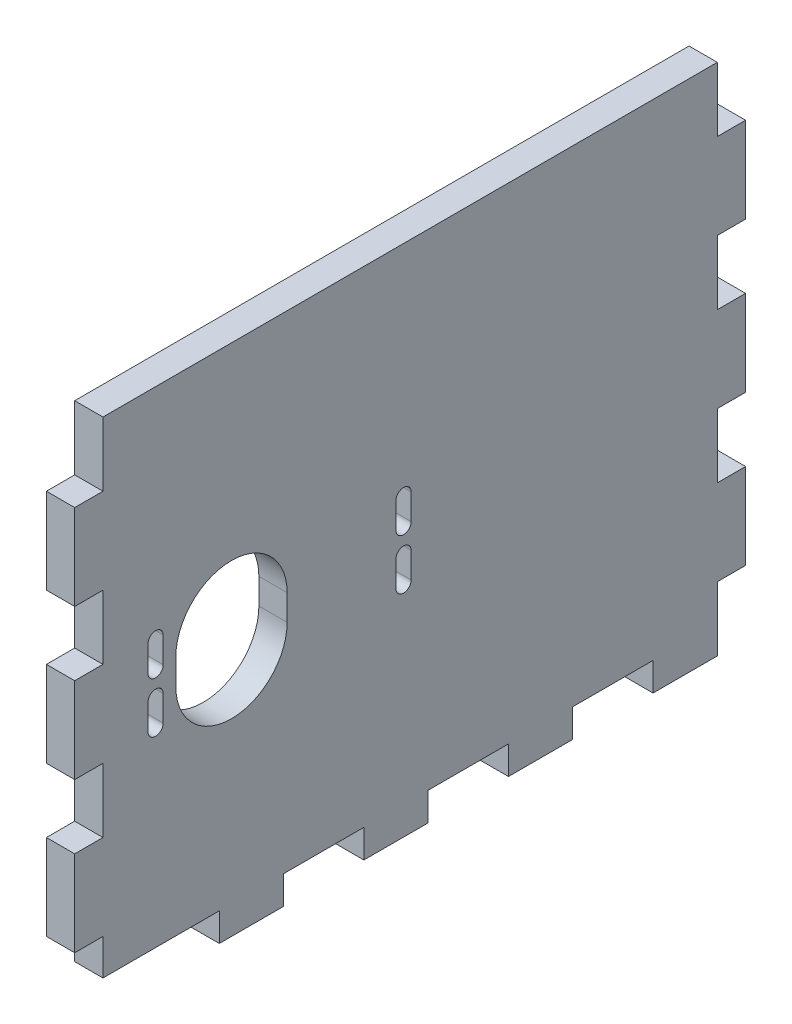
from build123d import *

# Parameters (mm, degrees)
SKETCH1_W               = 44.958
SKETCH1_H               = 304.8
BOSS_EXTRUDE1_DEPTH     = 5.588
BOSS_EXTRUDE2_DEPTH     = 5.588
SKETCH3_W               = 121.412
SKETCH3_H               = 5.588
BOSS_EXTRUDE3_DEPTH     = 39.37
SKETCH8_W               = 5.588
SKETCH8_H               = 213.451350416
CUT_EXTRUDE4_DEPTH      = 1
CUT_EXTRUDE4_DEPTH_BACK = 133.588
SKETCH6_W               = 5.588
SKETCH6_H               = 12.7
CUT_EXTRUDE5_DEPTH      = 5.588
SKETCH4_3_W             = 6.35
SKETCH4_3_H             = 15.875
SKETCH4_3_H_2           = 5.588
SKETCH4_3_H_3           = 7.112
CUT_EXTRUDE6_DEPTH      = 5.588


with BuildPart() as part:
    # Sketch1 → Boss-Extrude1 (new body)
    with BuildSketch(Plane.XY):
        with Locations((-6.477, 3.048)):
            Rectangle(SKETCH1_W, SKETCH1_H)
        with BuildLine():
            Line((-3.302, 133.858), (-3.302, -143.002))
            Line((-3.302, -143.002), (3.302, -143.002))
            Line((3.302, -143.002), (3.302, 143.002))
            Line((3.302, 143.002), (-16.256, 143.002))
            Line((-16.256, 143.002), (-16.256, 136.398))
            Line((-16.256, 136.398), (-5.842, 136.398))
            ThreePointArc((-5.842, 136.398), (-4.045948776, 135.654051224), (-3.302, 133.858))
        make_face(mode=Mode.SUBTRACT)
    extrude(amount=BOSS_EXTRUDE1_DEPTH)

    # Sketch2 → Boss-Extrude2 (add)
    with BuildSketch(Plane(origin=(16.002, 0, 0), x_dir=(0, 0, -1), z_dir=(1, 0, 0))):
        Polygon((121.412, -47.752), (-5.588, -47.752), (-5.588, -149.352), (121.412, -149.352), (121.412, -136.652), (127, -136.652), (127, -119.718666667), (121.412, -119.718666667), (121.412, -107.018666667), (127, -107.018666667), (127, -90.085333333), (121.412, -90.085333333), (121.412, -77.385333333), (127, -77.385333333), (127, -60.452), (121.412, -60.452), align=None)
        with BuildLine():
            ThreePointArc((11.9, -106.092), (10.4, -107.592), (8.9, -106.092))
            Line((8.9, -106.092), (8.9, -101.012))
            ThreePointArc((8.9, -101.012), (10.4, -99.512), (11.9, -101.012))
            Line((11.9, -101.012), (11.9, -106.092))
        make_face(mode=Mode.SUBTRACT)
        with BuildLine():
            ThreePointArc((60.9, -106.092), (59.4, -107.592), (57.9, -106.092))
            Line((57.9, -106.092), (57.9, -101.012))
            ThreePointArc((57.9, -101.012), (59.4, -99.512), (60.9, -101.012))
            Line((60.9, -101.012), (60.9, -106.092))
        make_face(mode=Mode.SUBTRACT)
        with BuildLine():
            Line((8.9, -96.092), (8.9, -91.012))
            ThreePointArc((8.9, -91.012), (10.4, -89.512), (11.9, -91.012))
            Line((11.9, -91.012), (11.9, -96.092))
            ThreePointArc((11.9, -96.092), (10.4, -97.592), (8.9, -96.092))
        make_face(mode=Mode.SUBTRACT)
        with BuildLine():
            ThreePointArc((36.4, -101.092), (25.4, -112.092), (14.4, -101.092))
            Line((14.4, -101.092), (14.4, -96.012))
            ThreePointArc((14.4, -96.012), (25.4, -85.012), (36.4, -96.012))
            Line((36.4, -96.012), (36.4, -101.092))
        make_face(mode=Mode.SUBTRACT)
        with BuildLine():
            ThreePointArc((57.9, -91.012), (59.4, -89.512), (60.9, -91.012))
            Line((60.9, -91.012), (60.9, -96.092))
            ThreePointArc((60.9, -96.092), (59.4, -97.592), (57.9, -96.092))
            Line((57.9, -96.092), (57.9, -91.012))
        make_face(mode=Mode.SUBTRACT)
    extrude(amount=-BOSS_EXTRUDE2_DEPTH)

    # Sketch3 → Boss-Extrude3 (add)
    with BuildSketch(Plane.ZY.offset(-10.414)):
        with Locations((-60.706, -146.558)):
            Rectangle(SKETCH3_W, SKETCH3_H)
    extrude(amount=BOSS_EXTRUDE3_DEPTH)

    # Sketch8 → Cut-Extrude4 (cut, two sides)
    with BuildSketch(Plane.XY.offset(5.588)) as cut_extrude4_sk:
        Polygon((-28.956, -149.352), (10.414, -149.352), (10.414, -47.752), (10.414, 155.448), (-28.956, 155.448), align=None)
        with BuildLine():
            Line((-16.256, 136.398), (-16.256, 143.002))
            Line((-16.256, 143.002), (3.302, 143.002))
            Line((3.302, 143.002), (3.302, -143.002))
            Line((3.302, -143.002), (-3.302, -143.002))
            Line((-3.302, -143.002), (-3.302, 133.858))
            ThreePointArc((-3.302, 133.858), (-4.045948776, 135.654051224), (-5.842, 136.398))
            Line((-5.842, 136.398), (-16.256, 136.398))
        make_face(mode=Mode.SUBTRACT)
        Polygon((-54.223542679, -149.352), (-28.956, -149.352), (-28.956, 155.448), (10.414, 155.448), (10.414, 165.699350416), (-54.223542679, 165.699350416), align=None)
        with Locations((13.208, 58.973675208)):
            Rectangle(SKETCH8_W, SKETCH8_H)
    extrude(amount=CUT_EXTRUDE4_DEPTH, mode=Mode.SUBTRACT)
    extrude(cut_extrude4_sk.sketch, amount=-CUT_EXTRUDE4_DEPTH_BACK, mode=Mode.SUBTRACT)

    # Sketch6 → Cut-Extrude5 (cut)
    with BuildSketch(Plane.XY.offset(5.588)):
        with Locations((13.208, -54.102)):
            Rectangle(SKETCH6_W, SKETCH6_H)
        with Locations((13.208, -83.735333333)):
            Rectangle(SKETCH6_W, SKETCH6_H)
        with Locations((13.208, -113.368666667)):
            Rectangle(SKETCH6_W, SKETCH6_H)
        with Locations((13.208, -143.002)):
            Rectangle(SKETCH6_W, SKETCH6_H)
    extrude(amount=-CUT_EXTRUDE5_DEPTH, mode=Mode.SUBTRACT)

    # Sketch4_3 → Cut-Extrude6 (cut)
    with BuildSketch(Plane.XZ.offset(149.352)):
        with Locations((12.827, -100.7745)):
            Rectangle(SKETCH4_3_W, SKETCH4_3_H)
        with Locations((12.827, -72.1995)):
            Rectangle(SKETCH4_3_W, SKETCH4_3_H)
        with Locations((12.827, -43.6245)):
            Rectangle(SKETCH4_3_W, SKETCH4_3_H)
        with Locations((12.827, -15.0495)):
            Rectangle(SKETCH4_3_W, SKETCH4_3_H)
        with Locations((12.827, 2.794)):
            Rectangle(SKETCH4_3_W, SKETCH4_3_H_2)
        with Locations((12.827, -3.556)):
            Rectangle(SKETCH4_3_W, SKETCH4_3_H_3)
    extrude(amount=-CUT_EXTRUDE6_DEPTH, mode=Mode.SUBTRACT)


solid = part.part
